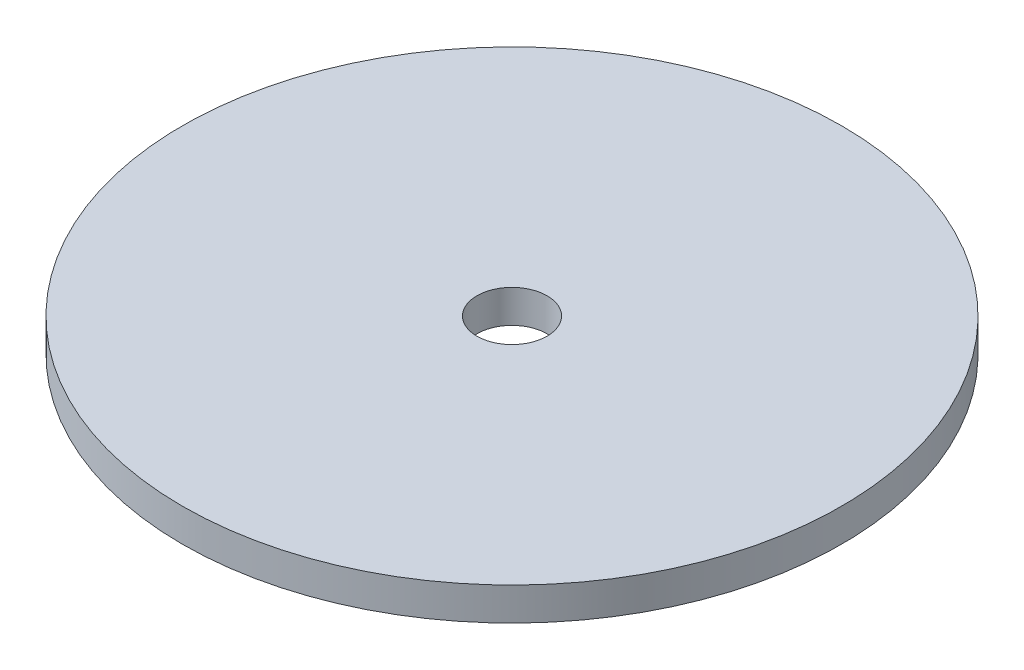
from build123d import *

# Parameters (mm, degrees)
SKETCH1_R           = 31.75
BOSS_EXTRUDE1_DEPTH = 1.5875
SKETCH2_R           = 3.3782
CUT_EXTRUDE1_DEPTH  = 4.175


with BuildPart() as part:
    # Sketch1 → Boss-Extrude1 (new body, symmetric)
    with BuildSketch(Plane(origin=(0, 0, 0), x_dir=(1, 0, 0), z_dir=(0, 1, 0))):
        Circle(SKETCH1_R)
    extrude(amount=BOSS_EXTRUDE1_DEPTH, both=True)

    # Sketch2 → Cut-Extrude1 (cut, through all)
    with BuildSketch(Plane(origin=(0, 1.5875, 0), x_dir=(1, 0, 0), z_dir=(0, 1, 0))):
        Circle(SKETCH2_R)
    extrude(amount=-CUT_EXTRUDE1_DEPTH, mode=Mode.SUBTRACT)


solid = part.part
